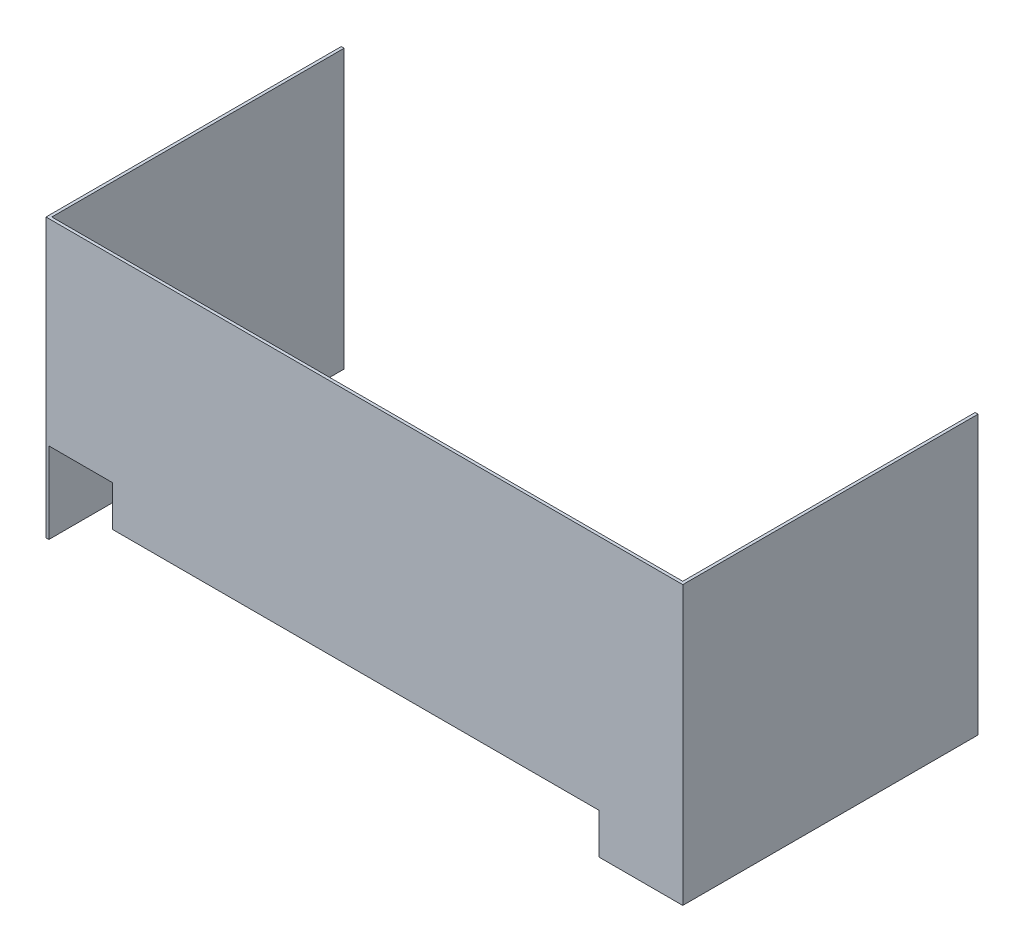
from build123d import *

# Parameters (mm, degrees)
EXTRUDE_THIN1_DEPTH = 304.8
SKETCH2_W           = 69.85
SKETCH2_H           = 88.9
CUT_EXTRUDE1_DEPTH  = 324.85
SKETCH3_W           = 533.4
SKETCH3_H           = 44.45
CUT_EXTRUDE2_DEPTH  = 4.175


with BuildPart() as part:
    # Sketch1 → Extrude-Thin1 (new body)
    with BuildSketch(Plane(origin=(0, 0, 0), x_dir=(1, 0, 0), z_dir=(0, 1, 0))):
        Polygon((-349.25, 196.85), (-349.25, -127), (-101.6, -127), (292.1, -127), (349.25, -127), (349.25, 196.85), (346.075, 196.85), (346.075, -123.825), (292.1, -123.825), (-101.6, -123.825), (-346.075, -123.825), (-346.075, 196.85), align=None)
    extrude(amount=EXTRUDE_THIN1_DEPTH)

    # Sketch2 → Cut-Extrude1 (cut, through all)
    with BuildSketch(Plane(origin=(-139.504532993, -186.632694872, 127), x_dir=(1, 0, 0), z_dir=(0, 0, 1))):
        with Locations((-171.645467007, 231.082694872)):
            Rectangle(SKETCH2_W, SKETCH2_H)
    extrude(amount=-CUT_EXTRUDE1_DEPTH, mode=Mode.SUBTRACT)

    # Sketch3 → Cut-Extrude2 (cut, through all)
    with BuildSketch(Plane(origin=(0, 0, 123.825), x_dir=(-1, 0, 0), z_dir=(0, 0, -1))):
        with Locations((9.525, 22.225)):
            Rectangle(SKETCH3_W, SKETCH3_H)
    extrude(amount=-CUT_EXTRUDE2_DEPTH, mode=Mode.SUBTRACT)


solid = part.part
